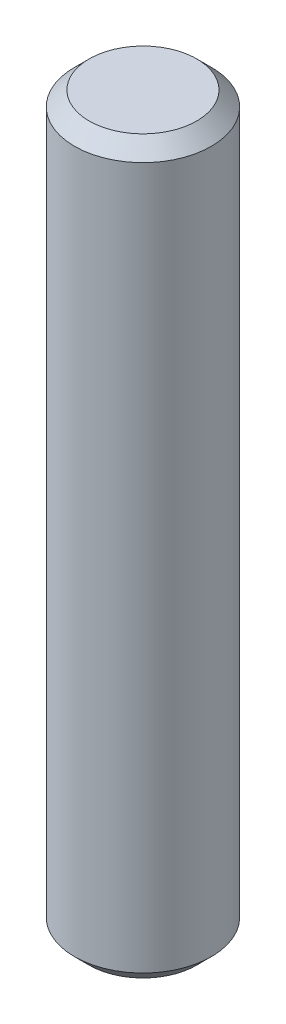
from build123d import *


with BuildPart() as part:
    # Sketch1 → Revolve1 (revolve)
    with BuildSketch(Plane(origin=(0, 0, 0), x_dir=(-1, 0, 0), z_dir=(0, 0, -1))):
        Polygon((-1.86944, 0), (0, 0), (0, 25.4), (-1.86944, 25.4), (-2.37744, 24.892), (-2.37744, 0.508), align=None)
    revolve(axis=Axis((0, 0, 0), (0, 1, 0)))


solid = part.part
